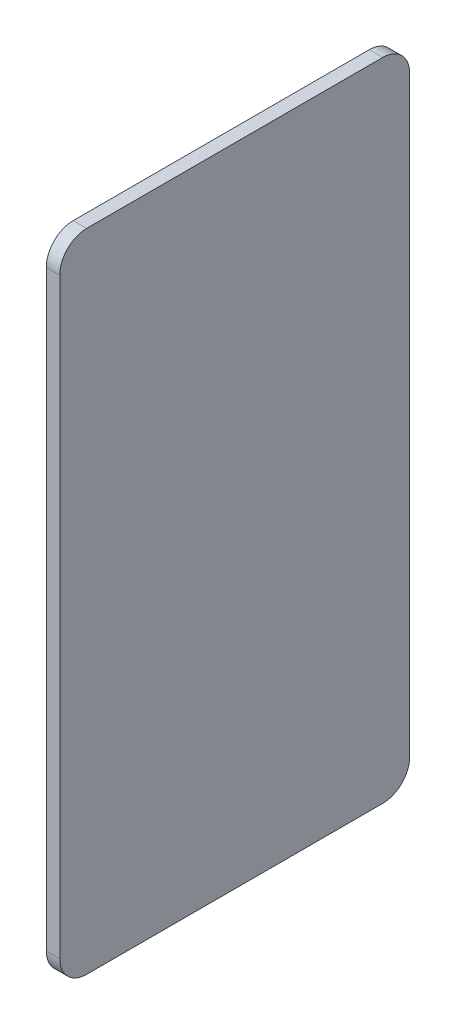
from build123d import *

# Parameters (mm, degrees)
SKETCH1_W           = 130
SKETCH1_H           = 240
BOSS_EXTRUDE1_DEPTH = 5
FILLET1_R           = 10


with BuildPart() as part:
    # Sketch1 → Boss-Extrude1 (new body)
    with BuildSketch(Plane(origin=(158.517331673, 0, 0), x_dir=(0, 0, -1), z_dir=(1, 0, 0))):
        with Locations((87.738499674, -11.228757924)):
            Rectangle(SKETCH1_W, SKETCH1_H)
    extrude(amount=-BOSS_EXTRUDE1_DEPTH)

    # Fillet1
    fillet1_edges = [part.edges().sort_by_distance(p)[0] for p in [
        (156.017331673, -131.228757924, -152.738499674),
        (156.017331673, -131.228757924, -22.738499674),
        (156.017331673, 108.771242076, -22.738499674),
        (156.017331673, 108.771242076, -152.738499674),
    ]]
    fillet(fillet1_edges, radius=FILLET1_R)


solid = part.part
